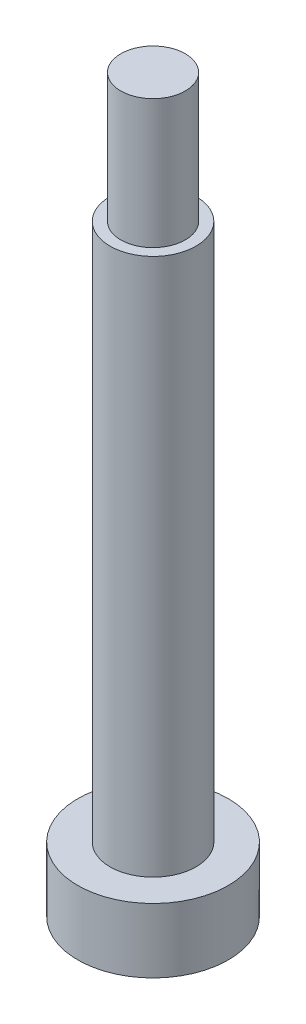
from build123d import *

# Parameters (mm, degrees)
SKETCH_1_R      = 2
EXTRUDE_1_DEPTH = 25
SKETCH_2_R      = 1.5
EXTRUDE_2_DEPTH = 6
SKETCH_3_R      = 3.5
EXTRUDE_3_DEPTH = 3


with BuildPart() as part:
    # 草图1 → 凸台-拉伸1 (new body)
    with BuildSketch(Plane(origin=(0, 0, 0), x_dir=(1, 0, 0), z_dir=(0, 1, 0))):
        Circle(SKETCH_1_R)
    extrude(amount=EXTRUDE_1_DEPTH)

    # 草图2 → 凸台-拉伸2 (add)
    with BuildSketch(Plane(origin=(0, 25, 0), x_dir=(1, 0, 0), z_dir=(0, 1, 0))):
        Circle(SKETCH_2_R)
    extrude(amount=EXTRUDE_2_DEPTH)

    # 草图3 → 凸台-拉伸3 (add)
    with BuildSketch(Plane.XZ):
        Circle(SKETCH_3_R)
    extrude(amount=EXTRUDE_3_DEPTH)


solid = part.part
